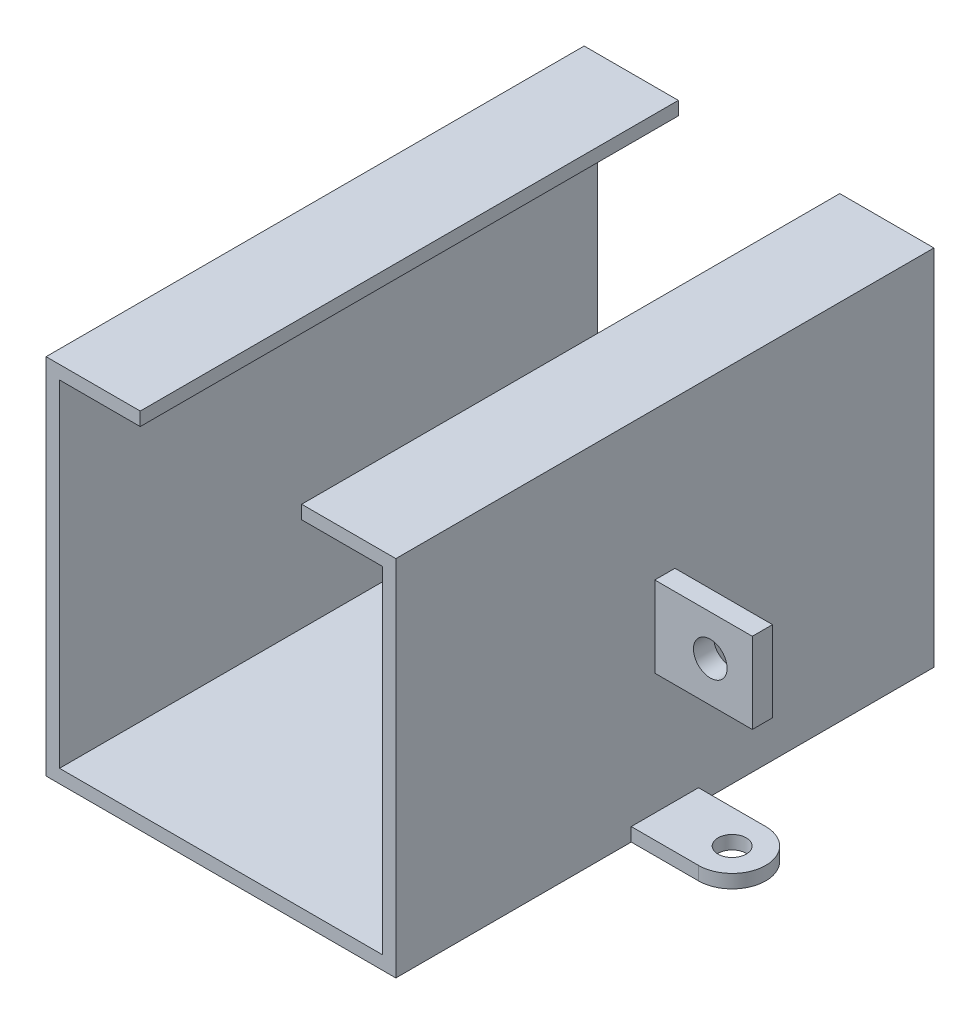
from build123d import *

# Parameters (mm, degrees)
BOSS_EXTRUDE1_DEPTH = 80
SKETCH2_R           = 2.1
BOSS_EXTRUDE2_DEPTH = 2
SKETCH3_W           = 3
SKETCH3_H           = 5
SKETCH3_H_2         = 7
BOSS_EXTRUDE3_DEPTH = 14.5
SKETCH5_W           = 3
SKETCH5_H           = 5
SKETCH5_H_2         = 7
BOSS_EXTRUDE4_DEPTH = 14.5
SKETCH8_R           = 2.5
CUT_EXTRUDE1_DEPTH  = 10


with BuildPart() as part:
    # Sketch1 → Boss-Extrude1 (new body)
    with BuildSketch(Plane.XY):
        Polygon((0, 0), (0, 50), (12, 50), (12, 52), (-2, 52), (-2, 25), (-2, -2), (50, -2), (50, 52), (36, 52), (36, 50), (48, 50), (48, 0), align=None)
    extrude(amount=BOSS_EXTRUDE1_DEPTH)

    # Sketch2 → Boss-Extrude2 (add)
    with BuildSketch(Plane.XZ.offset(2)):
        with BuildLine():
            Line((60, 45), (50, 45))
            Line((50, 45), (50, 35))
            Line((50, 35), (60, 35))
            ThreePointArc((60, 35), (65, 40), (60, 45))
        make_face()
        with Locations((60, 40)):
            Circle(SKETCH2_R, mode=Mode.SUBTRACT)
        with BuildLine():
            Line((-2, 35), (-2, 45))
            Line((-2, 45), (-12, 45))
            ThreePointArc((-12, 45), (-17, 40), (-12, 35))
            Line((-12, 35), (-2, 35))
        make_face()
        with Locations((-12, 40)):
            Circle(SKETCH2_R, mode=Mode.SUBTRACT)
    extrude(amount=-BOSS_EXTRUDE2_DEPTH)

    # Sketch3 → Boss-Extrude3 (add)
    with BuildSketch(Plane.ZY.offset(2)):
        with Locations((40, 27.5)):
            Rectangle(SKETCH3_W, SKETCH3_H)
        with Locations((40, 21.5)):
            Rectangle(SKETCH3_W, SKETCH3_H_2)
    extrude(amount=BOSS_EXTRUDE3_DEPTH)

    # Sketch5 → Boss-Extrude4 (add)
    with BuildSketch(Plane(origin=(50, 0, 0), x_dir=(0, 0, -1), z_dir=(1, 0, 0))):
        with Locations((-40, 27.5)):
            Rectangle(SKETCH5_W, SKETCH5_H)
        with Locations((-40, 21.5)):
            Rectangle(SKETCH5_W, SKETCH5_H_2)
    extrude(amount=BOSS_EXTRUDE4_DEPTH)

    # Sketch8 → Cut-Extrude1 (cut)
    with BuildSketch(Plane(origin=(0, 0, 38.5), x_dir=(-1, 0, 0), z_dir=(0, 0, -1))):
        with Locations((-58.25, 24)):
            Circle(SKETCH8_R)
        with Locations((10.25, 24)):
            Circle(SKETCH8_R)
    extrude(amount=-CUT_EXTRUDE1_DEPTH, mode=Mode.SUBTRACT)


solid = part.part
